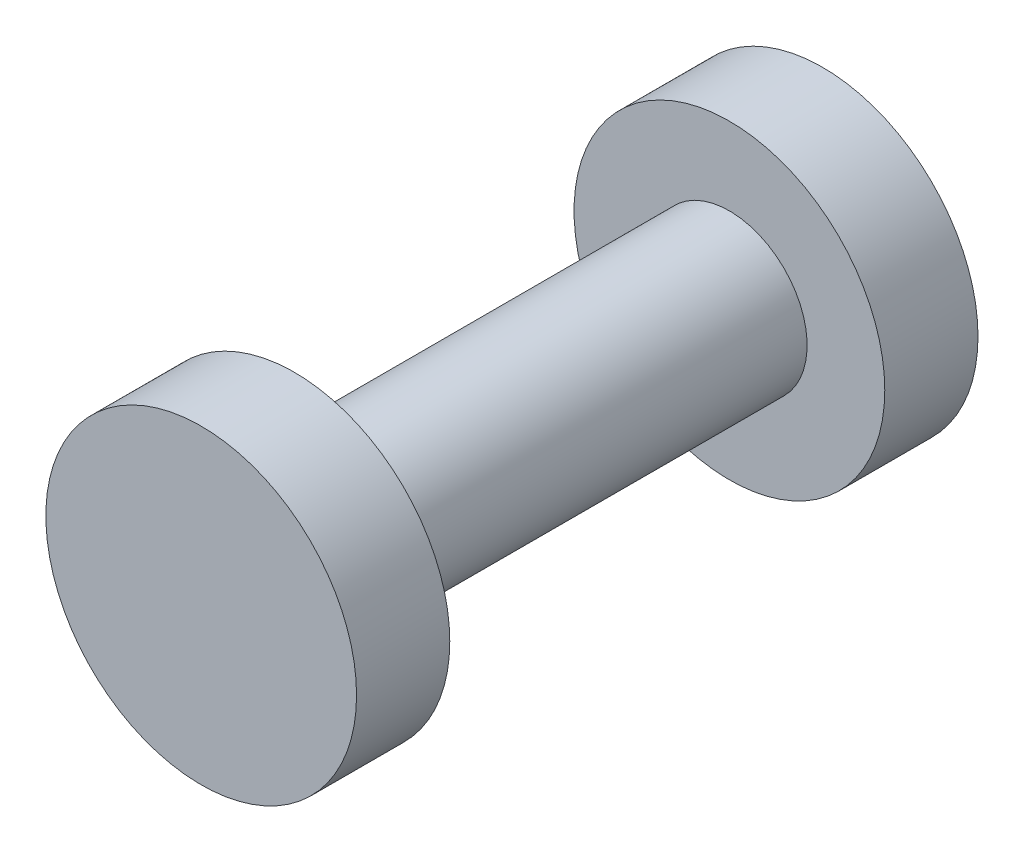
from build123d import *

# Parameters (mm, degrees)
SKETCH1_R           = 1.5
BOSS_EXTRUDE1_DEPTH = 6
SKETCH2_R           = 3
BOSS_EXTRUDE2_DEPTH = 1.8


with BuildPart() as part:
    # Sketch1 → Boss-Extrude1 (new body, symmetric)
    with BuildSketch(Plane.XY):
        Circle(SKETCH1_R)
    extrude(amount=BOSS_EXTRUDE1_DEPTH, both=True)

    # Sketch2 → Boss-Extrude2 (add)
    with BuildSketch(Plane.XY.offset(6)):
        Circle(SKETCH2_R)
    boss_extrude2 = extrude(amount=-BOSS_EXTRUDE2_DEPTH)

    # Mirror1: Boss-Extrude2 across plane
    add(boss_extrude2.mirror(Plane.XY))


solid = part.part
